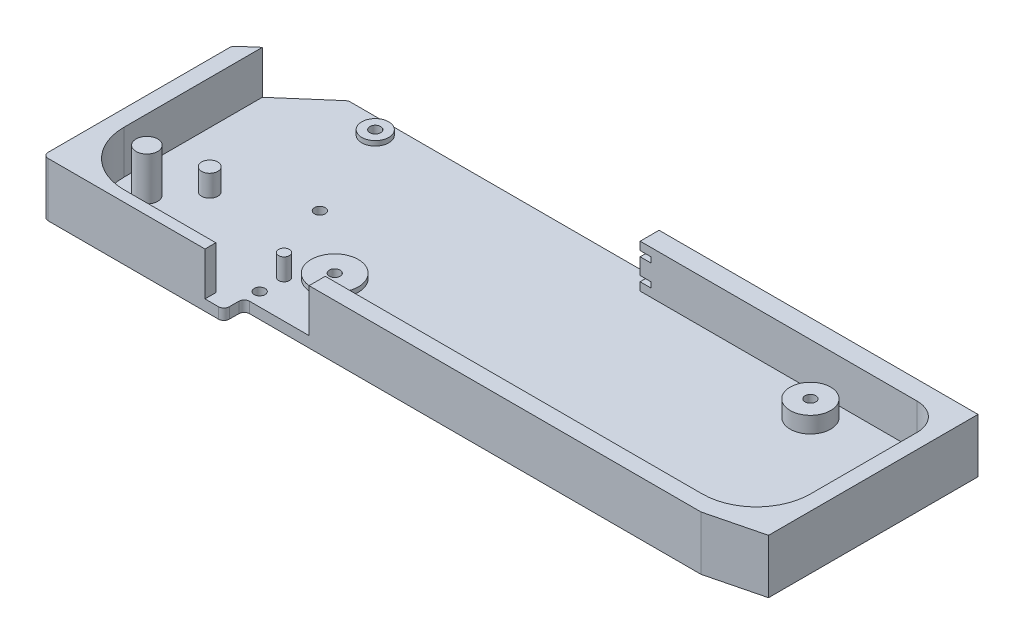
from build123d import *

# Parameters (mm, degrees)
SKETCH1_R               = 2
PRIMARY_DEPTH           = 4
SKETCH3_R               = 3
SKETCH3_R_2             = 2
STOP_EXT_DEPTH          = 8
FRONT_EXT_DEPTH         = 16
CUT_EXTRUDE1_START      = -7
SKETCH5_W               = 4
SKETCH5_H               = 2
CUT_EXTRUDE1_DEPTH      = 8
SKETCH6_W               = 2
SKETCH6_H               = 6
CUT_EXTRUDE2_DEPTH      = 3
SKETCH7_R               = 7.5
SKETCH7_R_2             = 2
SWINGYBIT_PIN_EXT_DEPTH = 6
SKETCH8_R               = 5
SKETCH8_R_2             = 2
SKETCH8_R_3             = 8.75
WHEEL_PIN_EXT_DEPTH     = 1.75
BOTTOM_EXT_DEPTH        = 16
FILLET1_R               = 2
SKETCH10_R              = 4
POST_EXT_DEPTH          = 16


with BuildPart() as part:
    # Sketch1 → Primary (new body)
    with BuildSketch(Plane(origin=(0, 0, 0), x_dir=(1, 0, 0), z_dir=(0, 1, 0))):
        Polygon((0, 0), (-23, -20), (-23, -90), (44, -90), (44, -82.5), (213, -82.5), (233, -77.5), (233, 0), align=None)
        with Locations((16, -6)):
            Circle(SKETCH1_R, mode=Mode.SUBTRACT)
        with Locations((30, -40.5)):
            Circle(SKETCH1_R, mode=Mode.SUBTRACT)
        with Locations((54.5, -59.5)):
            Circle(SKETCH1_R, mode=Mode.SUBTRACT)
        with Locations((44.75, -77.5)):
            Circle(SKETCH1_R, mode=Mode.SUBTRACT)
        with Locations((187, -16)):
            Circle(SKETCH1_R, mode=Mode.SUBTRACT)
    extrude(amount=PRIMARY_DEPTH)

    # Sketch3 → Stop Ext (add)
    with BuildSketch(Plane(origin=(0, 4, 0), x_dir=(1, 0, 0), z_dir=(0, 1, 0))):
        with Locations((3.5, -54.75)):
            Circle(SKETCH3_R)
        with Locations((44.75, -68.5)):
            Circle(SKETCH3_R_2)
    extrude(amount=STOP_EXT_DEPTH)

    # Sketch4 → Front Ext (add)
    with BuildSketch(Plane(origin=(0, 4, 0), x_dir=(1, 0, 0), z_dir=(0, 1, 0))):
        with BuildLine():
            Line((233, 0), (115, 0))
            Line((115, 0), (115, -7))
            Line((115, -7), (217.5, -7))
            ThreePointArc((217.5, -7), (224.571067812, -9.928932188), (227.5, -17))
            Line((227.5, -17), (227.5, -56.5))
            ThreePointArc((227.5, -56.5), (221.642135624, -70.642135624), (207.5, -76.5))
            Line((207.5, -76.5), (68, -76.5))
            Line((68, -76.5), (68, -82.5))
            Line((68, -82.5), (213, -82.5))
            Line((213, -82.5), (233, -77.5))
            Line((233, -77.5), (233, 0))
        make_face()
    extrude(amount=FRONT_EXT_DEPTH)

    # Sketch5 → Cut-Extrude1 (cut, through all)
    with BuildSketch(Plane(origin=(0, 0, 0), x_dir=(-1, 0, 0), z_dir=(0, 0, -1)).offset(CUT_EXTRUDE1_START)):
        with Locations((-117, 8)):
            Rectangle(SKETCH5_W, SKETCH5_H)
        with Locations((-117, 16)):
            Rectangle(SKETCH5_W, SKETCH5_H)
    extrude(amount=CUT_EXTRUDE1_DEPTH, mode=Mode.SUBTRACT)

    # Sketch6 → Cut-Extrude2 (cut)
    with BuildSketch(Plane(origin=(0, 0, 0), x_dir=(-1, 0, 0), z_dir=(0, 0, -1))):
        with Locations((-118, 12)):
            Rectangle(SKETCH6_W, SKETCH6_H)
    extrude(amount=-CUT_EXTRUDE2_DEPTH, mode=Mode.SUBTRACT)

    # Sketch7 → Swingybit_Pin Ext (add)
    with BuildSketch(Plane(origin=(0, 4, 0), x_dir=(1, 0, 0), z_dir=(0, 1, 0))):
        with Locations((187, -16)):
            Circle(SKETCH7_R)
        with Locations((187, -16)):
            Circle(SKETCH7_R_2, mode=Mode.SUBTRACT)
    extrude(amount=SWINGYBIT_PIN_EXT_DEPTH)

    # Sketch8 → Wheel_Pin Ext (add)
    with BuildSketch(Plane(origin=(0, 4, 0), x_dir=(1, 0, 0), z_dir=(0, 1, 0))):
        with Locations((16, -6)):
            Circle(SKETCH8_R)
        with Locations((16, -6)):
            Circle(SKETCH8_R_2, mode=Mode.SUBTRACT)
        with Locations((54.5, -59.5)):
            Circle(SKETCH8_R_3)
        with Locations((54.5, -59.5)):
            Circle(SKETCH8_R_2, mode=Mode.SUBTRACT)
    extrude(amount=WHEEL_PIN_EXT_DEPTH)

    # Sketch9 → Bottom Ext (add)
    with BuildSketch(Plane(origin=(0, 4, 0), x_dir=(1, 0, 0), z_dir=(0, 1, 0))):
        with BuildLine():
            Line((-23, -20), (-23, -86))
            Line((-23, -86), (-23, -90))
            Line((-23, -90), (37, -90))
            Line((37, -90), (37, -86))
            Line((37, -86), (3, -86))
            ThreePointArc((3, -86), (-11.142135624, -80.142135624), (-17, -66))
            Line((-17, -66), (-17, -14.782608696))
            Line((-17, -14.782608696), (-23, -20))
        make_face()
    extrude(amount=BOTTOM_EXT_DEPTH)

    # Fillet1
    fillet1_edges = [part.edges().sort_by_distance(p)[0] for p in [
        (44, 2, 82.5),
        (0, 2, 0),
        (-23, 10, 20),
        (-23, 10, 90),
        (44, 2, 90),
    ]]
    fillet(fillet1_edges, radius=FILLET1_R)

    # Sketch10 → Post Ext (add)
    with BuildSketch(Plane(origin=(0, 4, 0), x_dir=(1, 0, 0), z_dir=(0, 1, 0))):
        with Locations((-7, -67.5)):
            Circle(SKETCH10_R)
    extrude(amount=POST_EXT_DEPTH)


solid = part.part
